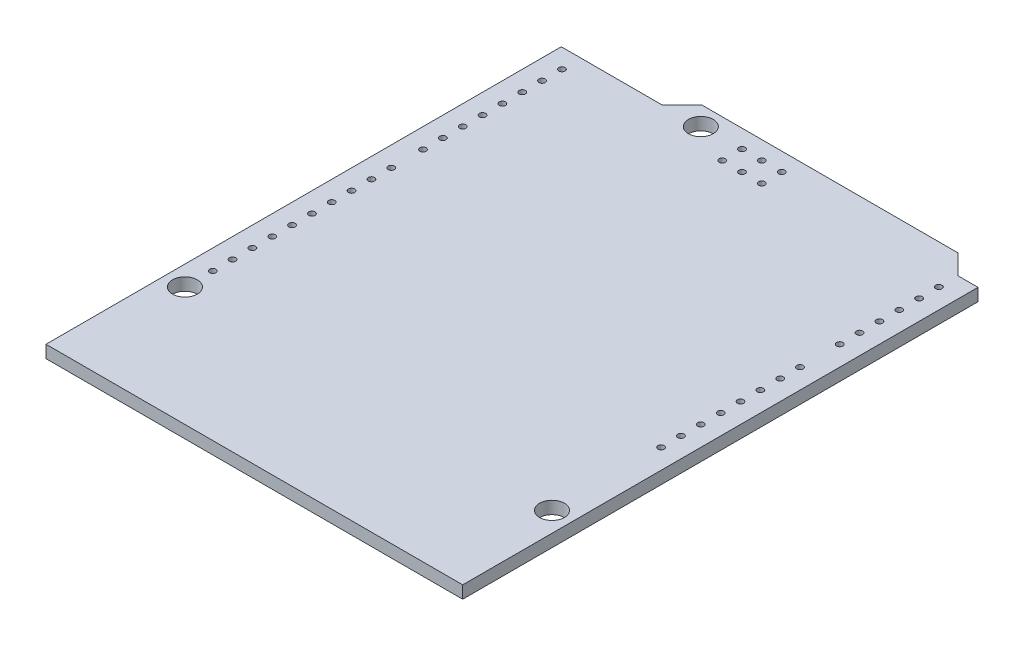
from build123d import *

# Parameters (mm, degrees)
SKETCH1_R           = 1.5875
BOSS_EXTRUDE1_DEPTH = 1.6
SKETCH2_R           = 0.4
CUT_EXTRUDE1_DEPTH  = 1.65
SKETCH3_R           = 0.4
CUT_EXTRUDE2_DEPTH  = 1.65
LPATTERN1_COUNT     = 15
LPATTERN1_PITCH     = 2.54
SKETCH4_R           = 0.4
CUT_EXTRUDE3_DEPTH  = 1.65
LPATTERN2_COUNT     = 10
LPATTERN2_PITCH     = 2.54
LPATTERN3_COUNT     = 17
LPATTERN3_PITCH     = 2.54
SKETCH5_R           = 0.4
CUT_EXTRUDE4_DEPTH  = 10


with BuildPart() as part:
    # Sketch1 → Boss-Extrude1 (new body)
    with BuildSketch(Plane(origin=(0, 0, 0), x_dir=(1, 0, 0), z_dir=(0, 1, 0))):
        Polygon((0, 0), (-53.34, 0), (-53.34, 65.96), (-40.386, 65.96), (-37.846, 68.5), (-5.08, 68.5), (-2.54, 65.96), (0, 65.96), align=None)
        with Locations((-35.56, 66.04)):
            Circle(SKETCH1_R, mode=Mode.SUBTRACT)
        with Locations((-2.54, 13.97)):
            Circle(SKETCH1_R, mode=Mode.SUBTRACT)
        with Locations((-50.8, 15.24)):
            Circle(SKETCH1_R, mode=Mode.SUBTRACT)
    extrude(amount=-BOSS_EXTRUDE1_DEPTH)

    # Sketch2 → Cut-Extrude1 (cut)
    with BuildSketch(Plane(origin=(0, 0, 0), x_dir=(1, 0, 0), z_dir=(0, 1, 0))):
        with Locations((-2.54, 27.94)):
            Circle(SKETCH2_R)
    cut_extrude1 = extrude(amount=-CUT_EXTRUDE1_DEPTH, mode=Mode.SUBTRACT)

    # Sketch3 → Cut-Extrude2 (cut)
    with BuildSketch(Plane(origin=(0, 0, 0), x_dir=(1, 0, 0), z_dir=(0, 1, 0))):
        with Locations((-50.8, 18.796)):
            Circle(SKETCH3_R)
    cut_extrude2 = extrude(amount=-CUT_EXTRUDE2_DEPTH, mode=Mode.SUBTRACT)

    # LPattern1: Cut-Extrude1 ×15, 1 skipped
    with Locations(*[(0, 0, -i * LPATTERN1_PITCH) for i in range(1, LPATTERN1_COUNT) if i not in (8,)]):
        add(cut_extrude1, mode=Mode.SUBTRACT)

    # Sketch4 → Cut-Extrude3 (cut)
    with BuildSketch(Plane(origin=(0, 0, 0), x_dir=(1, 0, 0), z_dir=(0, 1, 0))):
        with Locations((-50.8, 45.72)):
            Circle(SKETCH4_R)
    cut_extrude3 = extrude(amount=-CUT_EXTRUDE3_DEPTH, mode=Mode.SUBTRACT)

    # LPattern2: Cut-Extrude2 ×10
    with Locations(*[(0, 0, -i * LPATTERN2_PITCH) for i in range(1, LPATTERN2_COUNT)]):
        add(cut_extrude2, mode=Mode.SUBTRACT)

    # LPattern3: Cut-Extrude3 ×17, 1 skipped
    with Locations(*[(0, 0, -i * LPATTERN3_PITCH) for i in range(1, LPATTERN3_COUNT) if i not in (8,)]):
        add(cut_extrude3, mode=Mode.SUBTRACT)

    # Sketch5 → Cut-Extrude4 (cut)
    with BuildSketch(Plane(origin=(0, 0, 0), x_dir=(1, 0, 0), z_dir=(0, 1, 0))):
        with Locations((-30.43, 66.18)):
            Circle(SKETCH5_R)
        with Locations((-27.89, 66.18)):
            Circle(SKETCH5_R)
        with Locations((-25.35, 66.18)):
            Circle(SKETCH5_R)
        with Locations((-25.35, 63.64)):
            Circle(SKETCH5_R)
        with Locations((-27.89, 63.64)):
            Circle(SKETCH5_R)
        with Locations((-30.43, 63.64)):
            Circle(SKETCH5_R)
    extrude(amount=-CUT_EXTRUDE4_DEPTH, mode=Mode.SUBTRACT)


solid = part.part
